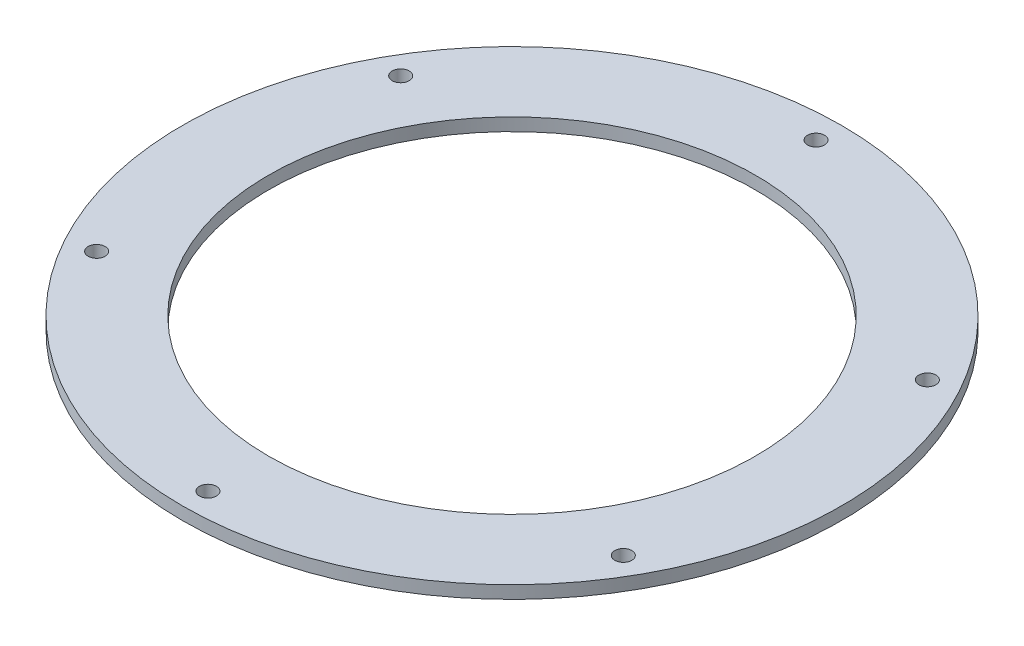
from build123d import *

# Parameters (mm, degrees)
SKETCH2_R           = 77.4975
SKETCH2_R_2         = 57.240625
SKETCH2_R_3         = 2
BOSS_EXTRUDE1_DEPTH = 3


with BuildPart() as part:
    # Sketch2 → Boss-Extrude1 (new body)
    with BuildSketch(Plane(origin=(0, 0, 0), x_dir=(1, 0, 0), z_dir=(0, 1, 0))):
        Circle(SKETCH2_R)
        Circle(SKETCH2_R_2, mode=Mode.SUBTRACT)
        with Locations((0, 71.5)):
            Circle(SKETCH2_R_3, mode=Mode.SUBTRACT)
        with Locations((61.920816371, 35.75)):
            Circle(SKETCH2_R_3, mode=Mode.SUBTRACT)
        with Locations((61.920816371, -35.75)):
            Circle(SKETCH2_R_3, mode=Mode.SUBTRACT)
        with Locations((0, -71.5)):
            Circle(SKETCH2_R_3, mode=Mode.SUBTRACT)
        with Locations((-61.920816371, -35.75)):
            Circle(SKETCH2_R_3, mode=Mode.SUBTRACT)
        with Locations((-61.920816371, 35.75)):
            Circle(SKETCH2_R_3, mode=Mode.SUBTRACT)
    extrude(amount=BOSS_EXTRUDE1_DEPTH)


solid = part.part
